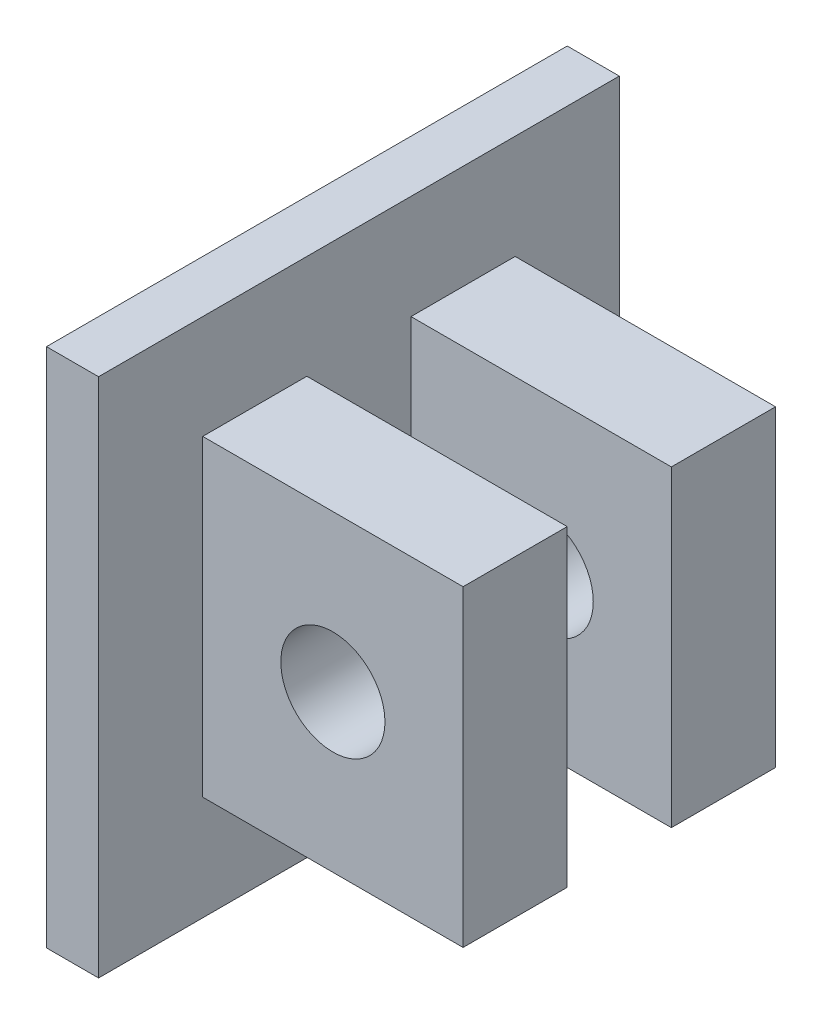
from build123d import *

# Parameters (mm, degrees)
SKETCH5_W           = 100
SKETCH5_H           = 100
BOSS_EXTRUDE3_DEPTH = 10
SKETCH6_W           = 20
SKETCH6_H           = 60
BOSS_EXTRUDE4_DEPTH = 50
SKETCH7_R           = 10
CUT_EXTRUDE2_DEPTH  = 60


with BuildPart() as part:
    # Sketch5 → Boss-Extrude3 (new body)
    with BuildSketch(Plane(origin=(0, 0, 0), x_dir=(0, 0, -1), z_dir=(1, 0, 0))):
        Rectangle(SKETCH5_W, SKETCH5_H)
    extrude(amount=BOSS_EXTRUDE3_DEPTH)

    # Sketch6 → Boss-Extrude4 (add)
    with BuildSketch(Plane(origin=(10, 0, 0), x_dir=(0, 0, -1), z_dir=(1, 0, 0))):
        with Locations((-20, 0.076080003)):
            Rectangle(SKETCH6_W, SKETCH6_H)
        with Locations((20, 0)):
            Rectangle(SKETCH6_W, SKETCH6_H)
    extrude(amount=BOSS_EXTRUDE4_DEPTH)

    # Sketch7 → Cut-Extrude2 (cut)
    with BuildSketch(Plane.XY.offset(30)):
        with Locations((35, 0.076080003)):
            Circle(SKETCH7_R)
    extrude(amount=-CUT_EXTRUDE2_DEPTH, mode=Mode.SUBTRACT)


solid = part.part
